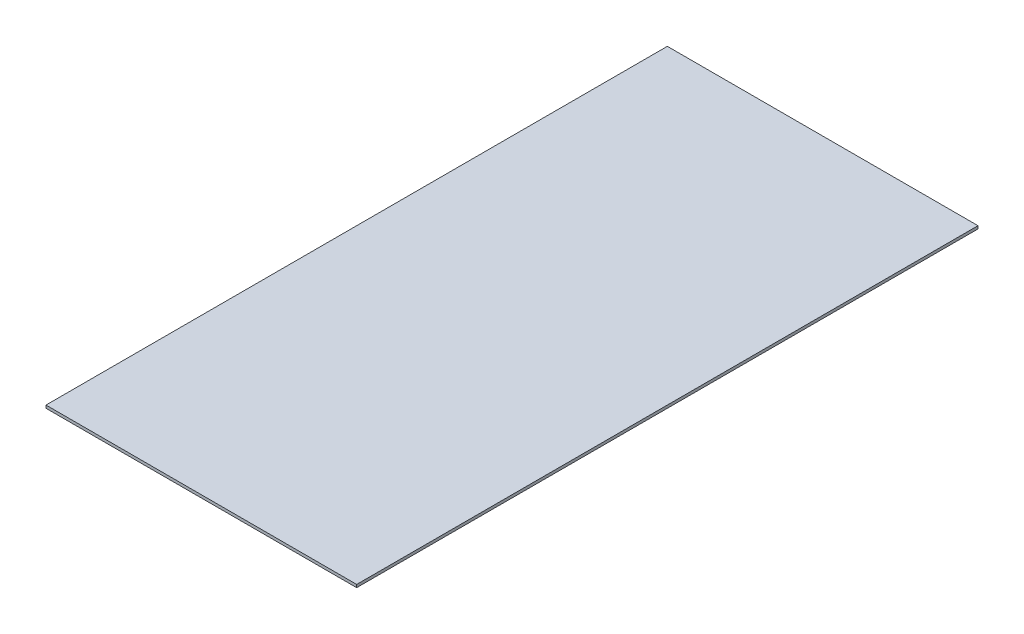
from build123d import *

# Parameters (mm, degrees)
SKETCH1_W           = 609.6
SKETCH1_H           = 1219.2
BOSS_EXTRUDE1_DEPTH = 5.55625


with BuildPart() as part:
    # Sketch1 → Boss-Extrude1 (new body)
    with BuildSketch(Plane(origin=(0, 0, 0), x_dir=(1, 0, 0), z_dir=(0, 1, 0))):
        Rectangle(SKETCH1_W, SKETCH1_H)
    extrude(amount=BOSS_EXTRUDE1_DEPTH)


solid = part.part
